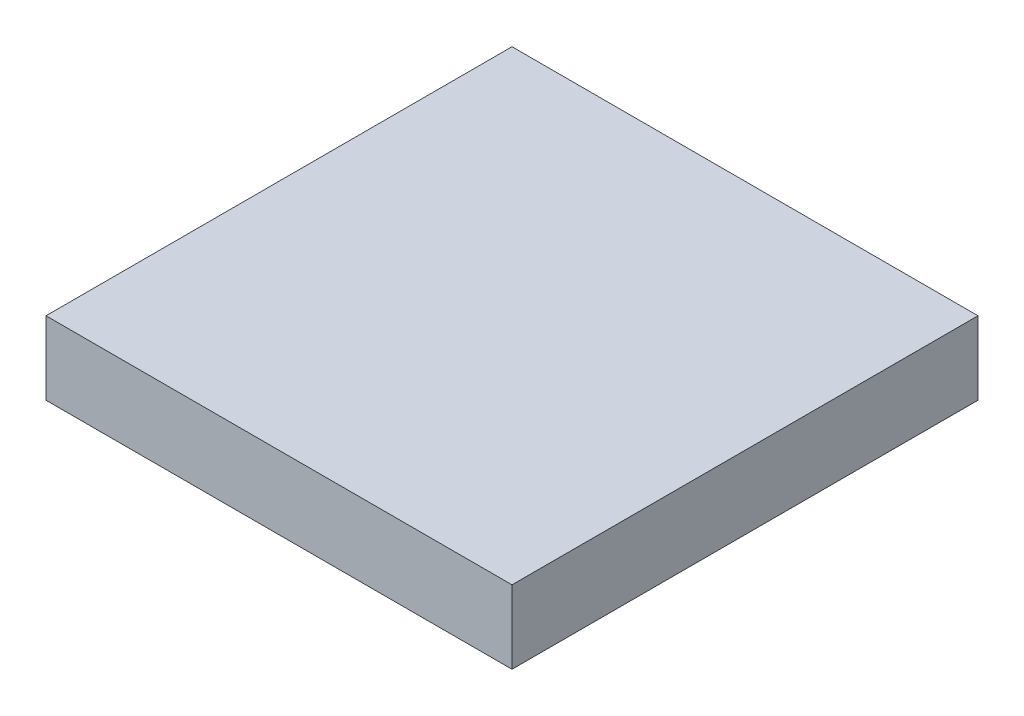
from build123d import *

# Parameters (mm, degrees)
SKETCH1_W           = 10
SKETCH1_H           = 10
BOSS_EXTRUDE1_DEPTH = 1.57


with BuildPart() as part:
    # Sketch1 → Boss-Extrude1 (new body)
    with BuildSketch(Plane(origin=(0, 0, 0), x_dir=(1, 0, 0), z_dir=(0, 1, 0))):
        with Locations((5, 5)):
            Rectangle(SKETCH1_W, SKETCH1_H)
    extrude(amount=BOSS_EXTRUDE1_DEPTH)


solid = part.part
